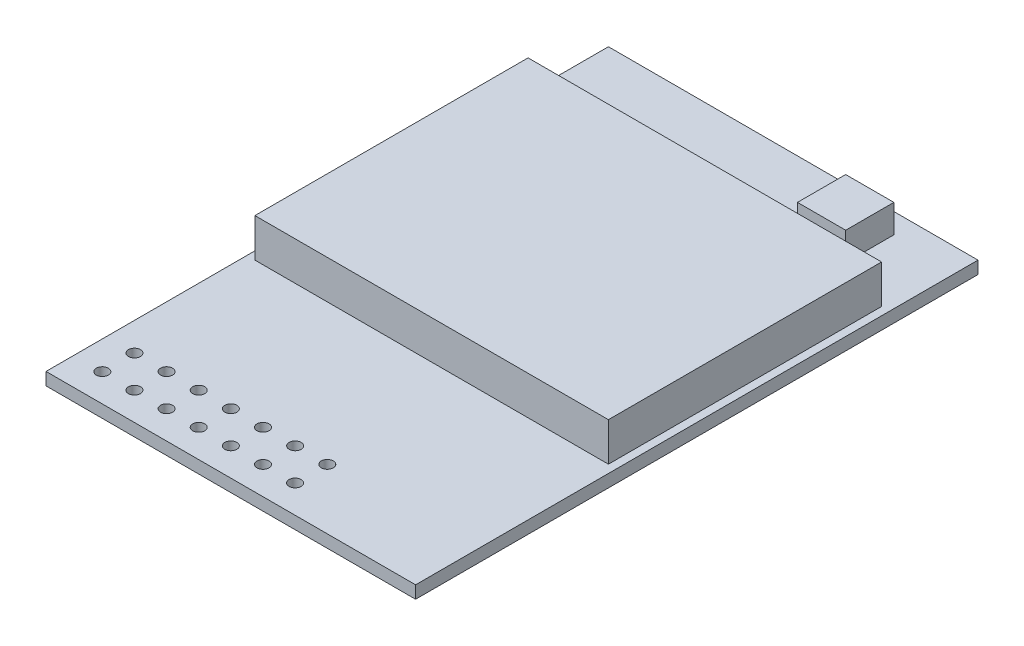
from build123d import *

# Parameters (mm, degrees)
SKETCH1_W           = 23
SKETCH1_H           = 35
BOSS_EXTRUDE1_DEPTH = 0.78
SKETCH2_W           = 22
SKETCH2_H           = 17
BOSS_EXTRUDE2_DEPTH = 2.4
SKETCH3_W           = 3
SKETCH3_H           = 3
BOSS_EXTRUDE3_DEPTH = 1.75
SKETCH4_R           = 0.375
CUT_EXTRUDE1_DEPTH  = 1.78


with BuildPart() as part:
    # Sketch1 → Boss-Extrude1 (new body)
    with BuildSketch(Plane(origin=(0, 0, 0), x_dir=(1, 0, 0), z_dir=(0, 1, 0))):
        Rectangle(SKETCH1_W, SKETCH1_H)
    extrude(amount=BOSS_EXTRUDE1_DEPTH)

    # Sketch2 → Boss-Extrude2 (add)
    with BuildSketch(Plane(origin=(0, 0.78, 0), x_dir=(1, 0, 0), z_dir=(0, 1, 0))):
        with Locations((0, 3.5)):
            Rectangle(SKETCH2_W, SKETCH2_H)
    extrude(amount=BOSS_EXTRUDE2_DEPTH)

    # Sketch3 → Boss-Extrude3 (add)
    with BuildSketch(Plane(origin=(0, 0.78, 0), x_dir=(1, 0, 0), z_dir=(0, 1, 0))):
        with Locations((6.021341325, 14.744149298)):
            Rectangle(SKETCH3_W, SKETCH3_H)
    extrude(amount=BOSS_EXTRUDE3_DEPTH)

    # Sketch4 → Cut-Extrude1 (cut, through all)
    with BuildSketch(Plane(origin=(0, 0.78, 0), x_dir=(1, 0, 0), z_dir=(0, 1, 0))):
        with Locations((-9.736937967, -15.759105546)):
            Circle(SKETCH4_R)
        with Locations((-7.736937967, -15.759105546)):
            Circle(SKETCH4_R)
        with Locations((-5.736937967, -15.759105546)):
            Circle(SKETCH4_R)
        with Locations((-3.736937967, -15.759105546)):
            Circle(SKETCH4_R)
        with Locations((-1.736937967, -15.759105546)):
            Circle(SKETCH4_R)
        with Locations((0.263062033, -15.759105546)):
            Circle(SKETCH4_R)
        with Locations((2.263062033, -15.759105546)):
            Circle(SKETCH4_R)
        with Locations((-7.736937967, -13.759105546)):
            Circle(SKETCH4_R)
        with Locations((-5.736937967, -13.759105546)):
            Circle(SKETCH4_R)
        with Locations((-3.736937967, -13.759105546)):
            Circle(SKETCH4_R)
        with Locations((-1.736937967, -13.759105546)):
            Circle(SKETCH4_R)
        with Locations((0.263062033, -13.759105546)):
            Circle(SKETCH4_R)
        with Locations((2.263062033, -13.759105546)):
            Circle(SKETCH4_R)
        with Locations((-9.736937967, -13.759105546)):
            Circle(SKETCH4_R)
    extrude(amount=-CUT_EXTRUDE1_DEPTH, mode=Mode.SUBTRACT)


solid = part.part
